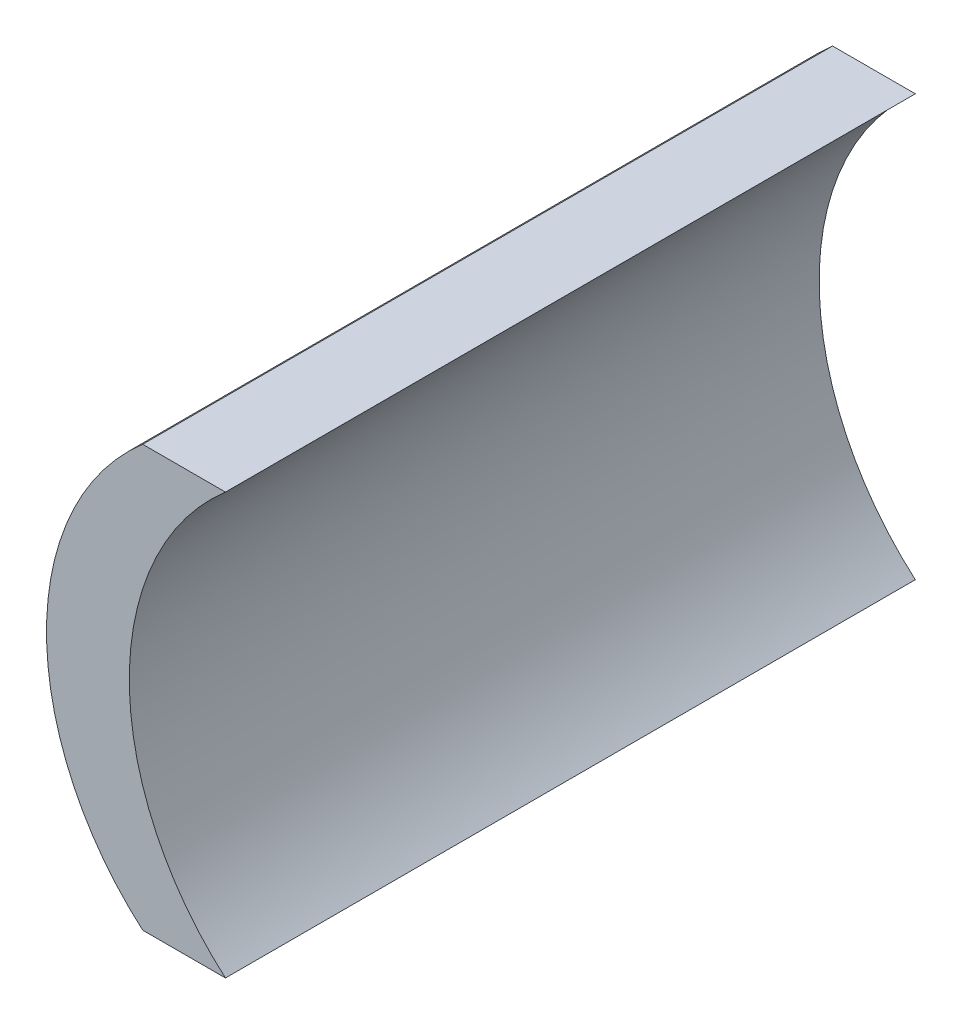
from build123d import *

# Parameters (mm, degrees)
BOSS_EXTRUDE1_DEPTH = 30


with BuildPart() as part:
    # Sketch2 → Boss-Extrude1 (new body)
    with BuildSketch(Plane.XY):
        with BuildLine():
            ThreePointArc((-11.517543811, 9.15), (-15.7, 0), (-11.517543811, -9.15))
            Line((-11.517543811, -9.15), (-7.917543811, -9.15))
            ThreePointArc((-7.917543811, -9.15), (-12.1, 0), (-7.917543811, 9.15))
            Line((-7.917543811, 9.15), (-11.517543811, 9.15))
        make_face()
    extrude(amount=BOSS_EXTRUDE1_DEPTH)


solid = part.part
